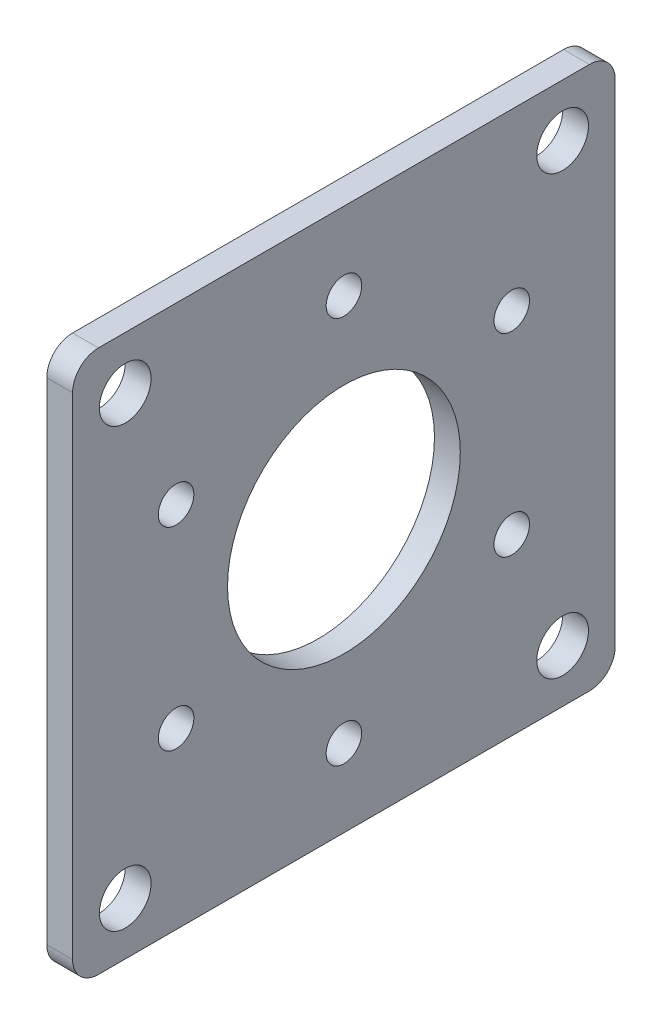
from build123d import *

# Parameters (mm, degrees)
SKETCH1_W           = 66.675
SKETCH1_H           = 66.675
SKETCH1_R           = 3.175
SKETCH1_R_2         = 14.3002
SKETCH1_R_3         = 2.1828125
BOSS_EXTRUDE1_DEPTH = 3.175
FILLET1_R           = 3.175


with BuildPart() as part:
    # Sketch1 → Boss-Extrude1 (new body)
    with BuildSketch(Plane(origin=(0, 0, 0), x_dir=(0, 0, -1), z_dir=(1, 0, 0))):
        Rectangle(SKETCH1_W, SKETCH1_H)
        with Locations((-26.870057685, 26.870057685)):
            Circle(SKETCH1_R, mode=Mode.SUBTRACT)
        with Locations((26.870057685, 26.870057685)):
            Circle(SKETCH1_R, mode=Mode.SUBTRACT)
        with Locations((26.870057685, -26.870057685)):
            Circle(SKETCH1_R, mode=Mode.SUBTRACT)
        with Locations((-26.870057685, -26.870057685)):
            Circle(SKETCH1_R, mode=Mode.SUBTRACT)
        Circle(SKETCH1_R_2, mode=Mode.SUBTRACT)
        with Locations((0, 23.8125)):
            Circle(SKETCH1_R_3, mode=Mode.SUBTRACT)
        with Locations((20.622229928, 11.90625)):
            Circle(SKETCH1_R_3, mode=Mode.SUBTRACT)
        with Locations((20.622229928, -11.90625)):
            Circle(SKETCH1_R_3, mode=Mode.SUBTRACT)
        with Locations((0, -23.8125)):
            Circle(SKETCH1_R_3, mode=Mode.SUBTRACT)
        with Locations((-20.622229928, -11.90625)):
            Circle(SKETCH1_R_3, mode=Mode.SUBTRACT)
        with Locations((-20.622229928, 11.90625)):
            Circle(SKETCH1_R_3, mode=Mode.SUBTRACT)
    extrude(amount=BOSS_EXTRUDE1_DEPTH)

    # Fillet1
    fillet1_edges = [part.edges().sort_by_distance(p)[0] for p in [
        (1.5875, -33.3375, -33.3375),
        (1.5875, -33.3375, 33.3375),
        (1.5875, 33.3375, 33.3375),
        (1.5875, 33.3375, -33.3375),
    ]]
    fillet(fillet1_edges, radius=FILLET1_R)


solid = part.part
